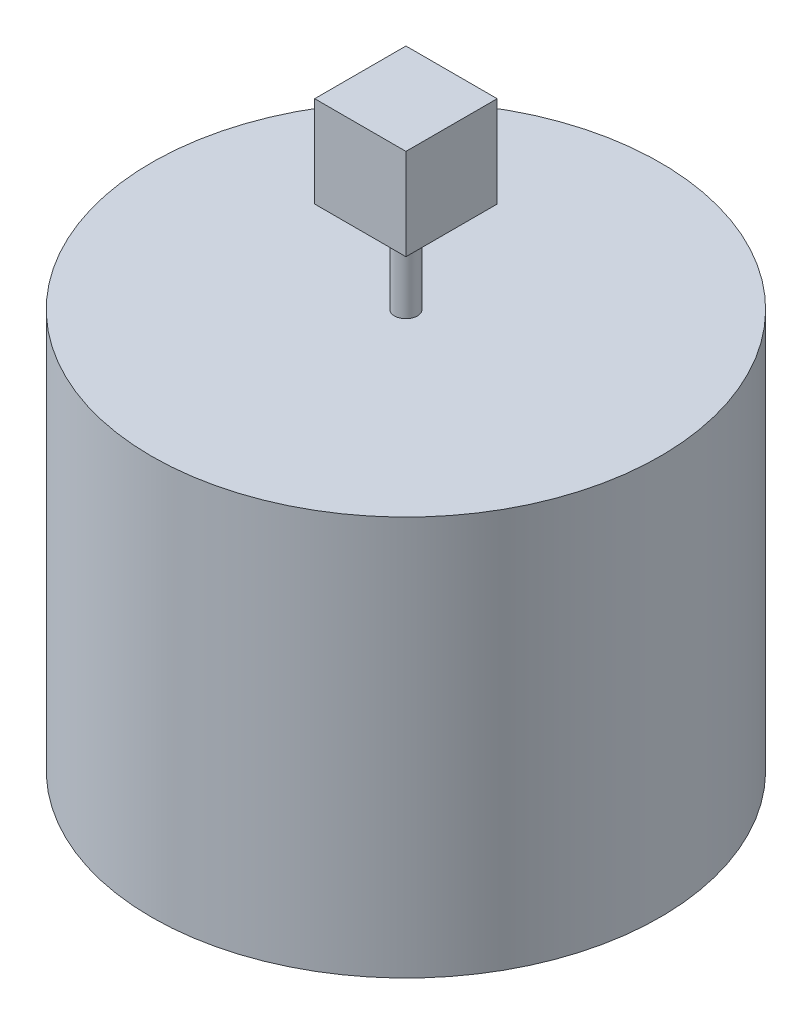
from build123d import *

# Parameters (mm, degrees)
ESQUISSE1_R      = 223
EXTRUSION1_DEPTH = 350
ESQUISSE2_R      = 10
EXTRUSION2_DEPTH = 80
ESQUISSE3_W      = 80
ESQUISSE3_H      = 80
EXTRUSION3_DEPTH = 80


with BuildPart() as part:
    # Esquisse1 → Extrusion1 (new body)
    with BuildSketch(Plane(origin=(0, 0, 0), x_dir=(1, 0, 0), z_dir=(0, 1, 0))):
        Circle(ESQUISSE1_R)
    extrude(amount=EXTRUSION1_DEPTH)

    # Esquisse2 → Extrusion2 (add)
    with BuildSketch(Plane(origin=(0, 350, 0), x_dir=(1, 0, 0), z_dir=(0, 1, 0))):
        Circle(ESQUISSE2_R)
    extrude(amount=EXTRUSION2_DEPTH)

    # Esquisse3 → Extrusion3 (add)
    with BuildSketch(Plane(origin=(0, 430, 0), x_dir=(1, 0, 0), z_dir=(0, 1, 0))):
        Rectangle(ESQUISSE3_W, ESQUISSE3_H)
    extrude(amount=EXTRUSION3_DEPTH)


solid = part.part
